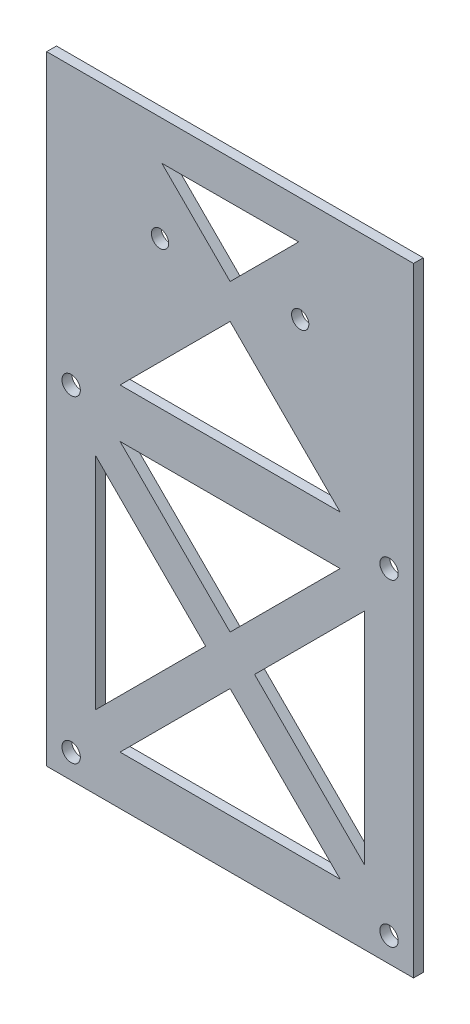
from build123d import *

# Parameters (mm, degrees)
SKETCH1_W           = 75
SKETCH1_H           = 126.51894577
SKETCH1_R           = 1.875
SKETCH1_R_2         = 1.765
BOSS_EXTRUDE2_DEPTH = 2


with BuildPart() as part:
    # Sketch1 → Boss-Extrude2 (new body)
    with BuildSketch(Plane.XY):
        with Locations((0, -201.288893998)):
            Rectangle(SKETCH1_W, SKETCH1_H)
        with Locations((32.5, -259.548366883)):
            Circle(SKETCH1_R, mode=Mode.SUBTRACT)
        with Locations((-32.5, -259.548366883)):
            Circle(SKETCH1_R, mode=Mode.SUBTRACT)
        with Locations((-32.5, -194.548366883)):
            Circle(SKETCH1_R, mode=Mode.SUBTRACT)
        with Locations((32.5, -194.548366883)):
            Circle(SKETCH1_R, mode=Mode.SUBTRACT)
        with Locations((14.329505719, -159.529421113)):
            Circle(SKETCH1_R_2, mode=Mode.SUBTRACT)
        with Locations((-14.329505719, -159.529421113)):
            Circle(SKETCH1_R_2, mode=Mode.SUBTRACT)
        Polygon((-27.5, -204.548366883), (-27.5, -249.548366883), (-5, -227.048366883), align=None, mode=Mode.SUBTRACT)
        Polygon((-22.5, -254.548366883), (22.5, -254.548366883), (0, -232.048366883), align=None, mode=Mode.SUBTRACT)
        Polygon((27.5, -249.548366883), (27.5, -204.548366883), (5, -227.048366883), align=None, mode=Mode.SUBTRACT)
        Polygon((-22.5, -199.548366883), (22.5, -199.548366883), (0, -222.048366883), align=None, mode=Mode.SUBTRACT)
        Polygon((-22.5, -189.548366883), (22.5, -189.548366883), (0, -167.048366883), align=None, mode=Mode.SUBTRACT)
        Polygon((14.024331064, -145.954035819), (0, -159.978366883), (-13.95827912, -146.020087763), align=None, mode=Mode.SUBTRACT)
    extrude(amount=BOSS_EXTRUDE2_DEPTH)


solid = part.part
